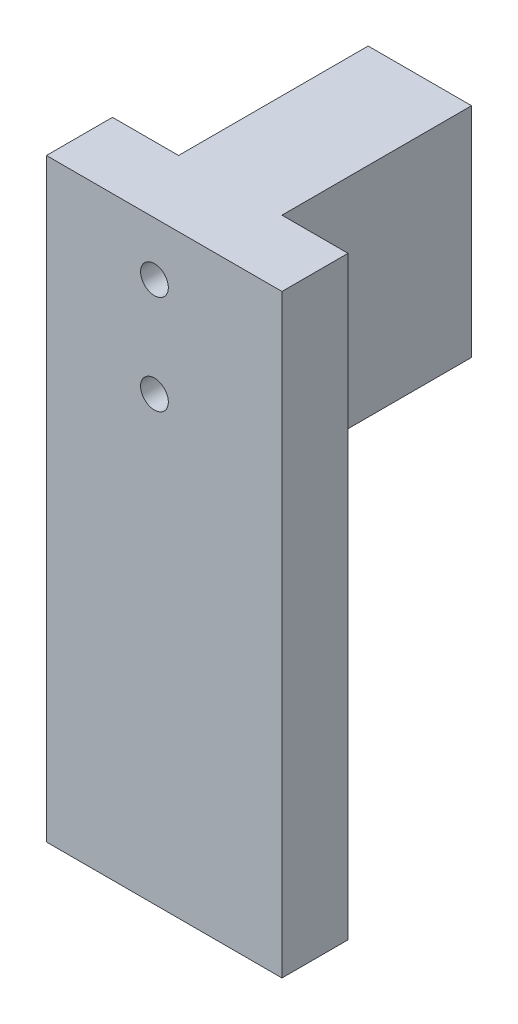
from build123d import *

# Parameters (mm, degrees)
SKETCH3_W             = 18.7
SKETCH3_H             = 18.7
SKETCH3_W_2           = 12.7
SKETCH3_H_2           = 12.7
BOSS_EXTRUDE2_DEPTH   = 30
SKETCH4_W             = 18.7
SKETCH4_H             = 18.7
BOSS_EXTRUDE3_DEPTH   = 3
SKETCH13_W            = 3.048327816
SKETCH13_H            = 18.7
CUT_EXTRUDE1_DEPTH    = 33
SKETCH16_W            = 15.651672184
SKETCH16_H            = 33
BOSS_EXTRUDE6_DEPTH   = 10
SKETCH17_W            = 35.651672184
SKETCH17_H            = 90
BOSS_EXTRUDE7_DEPTH   = 10
M5X0_8_TAPPED_HOLE1_D = 4.2


with BuildPart() as part:
    # Sketch3 → Boss-Extrude2 (new body)
    with BuildSketch(Plane(origin=(0, 0, 0), x_dir=(1, 0, 0), z_dir=(0, 1, 0))):
        with Locations((9.35, 9.35)):
            Rectangle(SKETCH3_W, SKETCH3_H)
        with Locations((9.35, 9.35)):
            Rectangle(SKETCH3_W_2, SKETCH3_H_2, mode=Mode.SUBTRACT)
    extrude(amount=BOSS_EXTRUDE2_DEPTH)

    # Sketch4 → Boss-Extrude3 (add)
    with BuildSketch(Plane(origin=(0, 30, 0), x_dir=(1, 0, 0), z_dir=(0, 1, 0))):
        with Locations((9.35, 9.35)):
            Rectangle(SKETCH4_W, SKETCH4_H)
    extrude(amount=BOSS_EXTRUDE3_DEPTH)

    # Sketch13 → Cut-Extrude1 (cut)
    with BuildSketch(Plane.XZ):
        with Locations((1.524163908, -9.35)):
            Rectangle(SKETCH13_W, SKETCH13_H)
    extrude(amount=-CUT_EXTRUDE1_DEPTH, mode=Mode.SUBTRACT)

    # Sketch16 → Boss-Extrude6 (add)
    with BuildSketch(Plane.XY):
        with Locations((10.874163908, 16.5)):
            Rectangle(SKETCH16_W, SKETCH16_H)
    extrude(amount=BOSS_EXTRUDE6_DEPTH)

    # Sketch17 → Boss-Extrude7 (add)
    with BuildSketch(Plane.XY.offset(10)):
        with Locations((10.874163908, -12)):
            Rectangle(SKETCH17_W, SKETCH17_H)
    extrude(amount=BOSS_EXTRUDE7_DEPTH)

    # M5x0.8 Tapped Hole1 (through all)
    with Locations(Plane(origin=(9.398327816, 24.9, -18.7), x_dir=(-1, 0, 0), z_dir=(0, 0, -1))):
        with Locations((0, 0), (0, -15)):
            Hole(M5X0_8_TAPPED_HOLE1_D / 2)


solid = part.part
